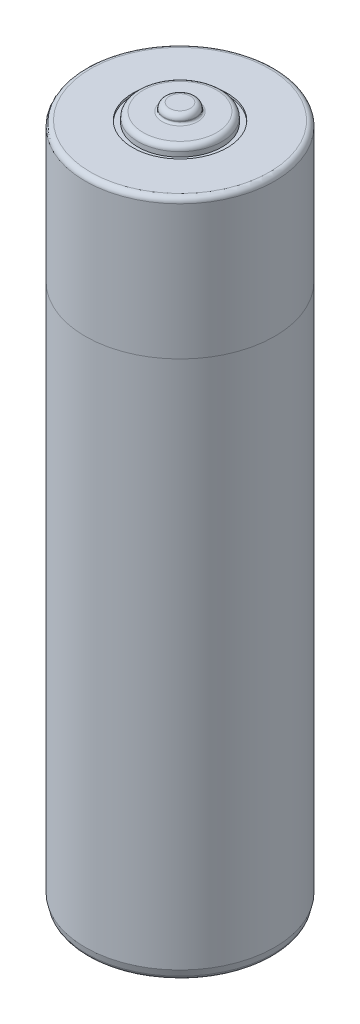
from build123d import *
from build123d.topology import SkipClean

# Parameters (mm, degrees)
SKETCH1_R      = 9.025
BASE_DEPTH     = 64.7
SKETCH7_R      = 4.5
SKETCH7_R_2    = 4
RIM_DEPTH      = 0.2
SKETCH2_R      = 1.5
TERMINAL_DEPTH = 1.5
SKETCH6_R      = 4
STEP_DEPTH     = 0.75
SKETCH3_R      = 3.35
SKETCH3_R_2    = 2.75
RIM_2_DEPTH    = 0.5
OUTER_FILLET_R = 0.5
INNER_FILLET_R = 0.2


with BuildPart() as part:
    # Sketch1 → Base (new body)
    with BuildSketch(Plane(origin=(0, 0, 0), x_dir=(1, 0, 0), z_dir=(0, 1, 0))):
        with Locations(Location((0, 0, 0), (0, 0, 270))):  # turned: the seam where the file's is
            Circle(SKETCH1_R)
    extrude(amount=BASE_DEPTH)

    # Sketch7 → Rim (cut)
    with BuildSketch(Plane(origin=(0, 64.7, 0), x_dir=(1, 0, 0), z_dir=(0, 1, 0))):
        Circle(SKETCH7_R)
        Circle(SKETCH7_R_2, mode=Mode.SUBTRACT)
    extrude(amount=-RIM_DEPTH, mode=Mode.SUBTRACT)

    # Sketch2 → Terminal (add)
    with BuildSketch(Plane(origin=(0, 64.7, 0), x_dir=(1, 0, 0), z_dir=(0, 1, 0))):
        with Locations(Location((0, 0, 0), (0, 0, 270))):  # turned: the seam where the file's is
            Circle(SKETCH2_R)
    extrude(amount=TERMINAL_DEPTH)

    # Sketch6 → Step (add)
    with SkipClean():  # keep this step's faces unmerged: merging them makes the solid invalid here
        with BuildSketch(Plane(origin=(0, 64.7, 0), x_dir=(1, 0, 0), z_dir=(0, 1, 0))):
            with Locations(Location((0, 0, 0), (0, 0, 270))):  # turned: the seam where the file's is
                Circle(SKETCH6_R)
        extrude(amount=STEP_DEPTH)

    # Sketch8 → Drop Off (revolve, cut)
    with SkipClean():  # keep this step's faces unmerged: merging them makes the solid invalid here
        with BuildSketch(Plane(origin=(0, 0, 0), x_dir=(0, 0, -1), z_dir=(1, 0, 0)), mode=Mode.PRIVATE) as drop_off_sk:
            Polygon((9.025, 1), (9.025, 0), (8.775, 0), align=None)
        revolve(drop_off_sk.sketch.rotate(Axis((0, 64.7, 0), (0, -1, 0)), 180), axis=Axis((0, 64.7, 0), (0, -1, 0)), mode=Mode.SUBTRACT)  # turned: the seam where the file's is

    # Sketch3 → Rim 2 (cut)
    with SkipClean():  # keep this step's faces unmerged: merging them makes the solid invalid here
        with BuildSketch(Plane.XZ):
            Circle(SKETCH3_R)
            Circle(SKETCH3_R_2, mode=Mode.SUBTRACT)
        extrude(amount=-RIM_2_DEPTH, mode=Mode.SUBTRACT)

    # Outer Fillet
    outer_fillet_edges = [part.edges().sort_by_distance(p)[0] for p in [
        (0, 66.2, -1.5),
        (0, 65.45, -4),
        (0, 0, -8.775),
        (0, 64.7, -9.025),
    ]]
    fillet(outer_fillet_edges, radius=OUTER_FILLET_R)

    # Inner Fillet
    inner_fillet_edges = [part.edges().sort_by_distance(p)[0] for p in [
        (0, 65.45, -1.5),
        (-2.75, 0.5, 0),
    ]]
    fillet(inner_fillet_edges, radius=INNER_FILLET_R)


solid = part.part
